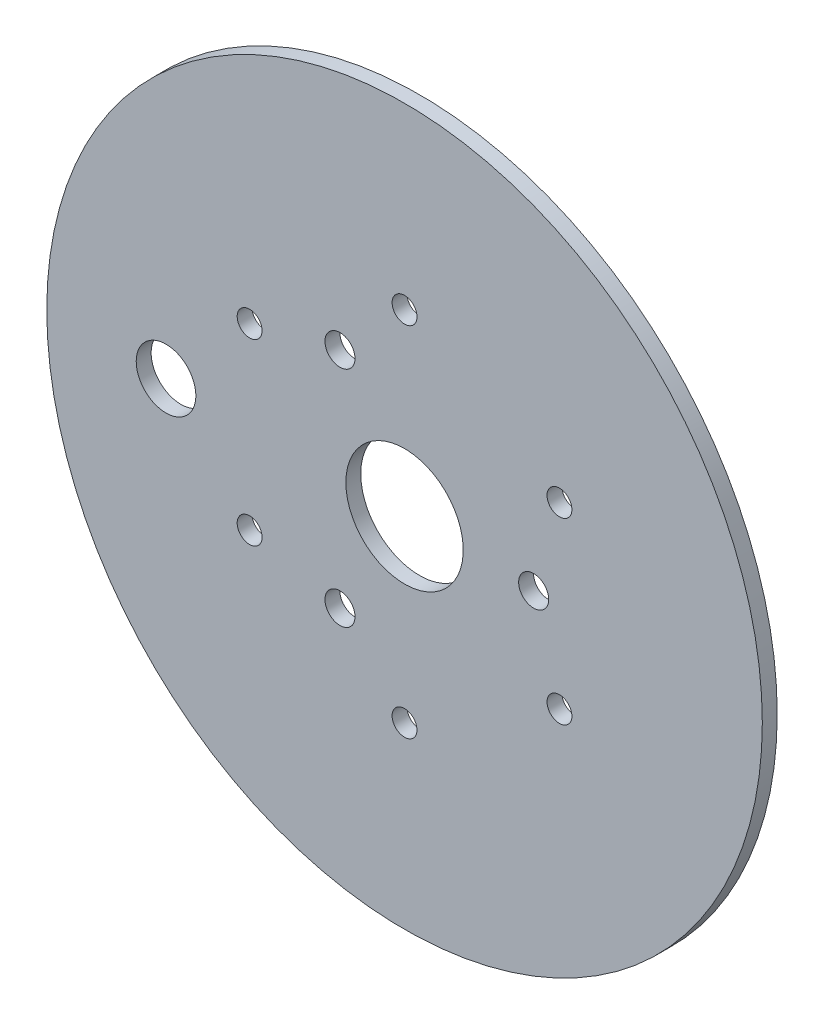
from build123d import *

# Parameters (mm, degrees)
SKETCH1_R           = 76.2
BOSS_EXTRUDE1_DEPTH = 3.175
CIRPATTERN1_COUNT   = 3
CIRPATTERN2_COUNT   = 6
SKETCH7_R           = 12.5
CUT_EXTRUDE2_DEPTH  = 4.175
SKETCH8_R           = 6.35
CUT_EXTRUDE3_DEPTH  = 4.175


with BuildPart() as part:
    # Sketch1 → Boss-Extrude1 (new body)
    with BuildSketch(Plane.XY):
        Circle(SKETCH1_R)
    extrude(amount=BOSS_EXTRUDE1_DEPTH)

    # Sketch4 → M5 Clearance Hole2 (revolve, cut)
    with BuildSketch(Plane(origin=(0, 38.1, 3.175), x_dir=(0, -1, 0), z_dir=(1, 0, 0))):
        Polygon((0, 0), (0, 14.03828064), (2.65, 12.446), (2.65, 0), align=None)
    m5_clearance_hole2 = revolve(axis=Axis((0, 38.1, 9.525), (0, 0, -1)), mode=Mode.SUBTRACT)

    # Sketch5 → M6 Clearance Hole1 (revolve, cut)
    with BuildSketch(Plane(origin=(-13.75, 23.815698604, 3.175), x_dir=(0, -1, 0), z_dir=(1, 0, 0))):
        Polygon((0, 0), (0, 14.368753981), (3.2, 12.446), (3.2, 0), align=None)
    m6_clearance_hole1 = revolve(axis=Axis((-13.75, 23.815698604, 9.525), (0, 0, -1)), mode=Mode.SUBTRACT)

    # CirPattern1: M6 Clearance Hole1 ×3 about axis
    cirpattern1_axis = Axis((0, 0, 0), (0, 0, 1))
    for i in range(1, CIRPATTERN1_COUNT):
        add(m6_clearance_hole1.rotate(cirpattern1_axis, i * 360 / CIRPATTERN1_COUNT), mode=Mode.SUBTRACT)

    # CirPattern2: M5 Clearance Hole2 ×6 about axis
    cirpattern2_axis = Axis((0, 0, 0), (0, 0, 1))
    for i in range(1, CIRPATTERN2_COUNT):
        add(m5_clearance_hole2.rotate(cirpattern2_axis, i * 360 / CIRPATTERN2_COUNT), mode=Mode.SUBTRACT)

    # Sketch7 → Cut-Extrude2 (cut, through all)
    with BuildSketch(Plane(origin=(0, 0, 0), x_dir=(-1, 0, 0), z_dir=(0, 0, -1))):
        Circle(SKETCH7_R)
    extrude(amount=-CUT_EXTRUDE2_DEPTH, mode=Mode.SUBTRACT)

    # Sketch8 → Cut-Extrude3 (cut, through all)
    with BuildSketch(Plane(origin=(0, 0, 0), x_dir=(-1, 0, 0), z_dir=(0, 0, -1))):
        with Locations((50.8, 0)):
            Circle(SKETCH8_R)
    extrude(amount=-CUT_EXTRUDE3_DEPTH, mode=Mode.SUBTRACT)


solid = part.part
